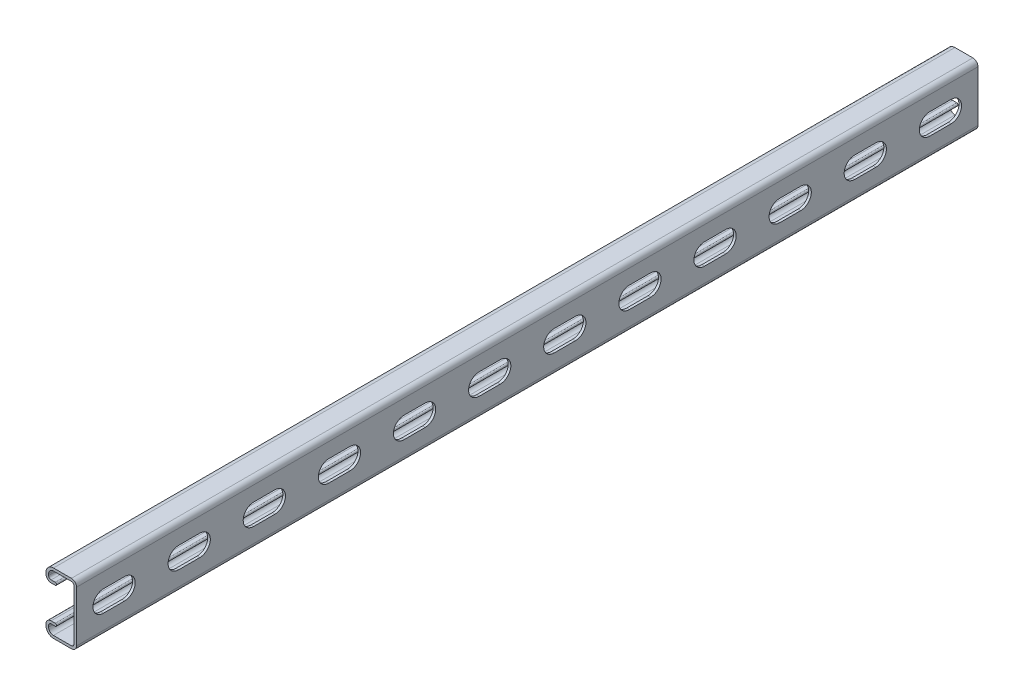
from build123d import *

# Parameters (mm, degrees)
BOSS_EXTRUDE1_DEPTH = 609.6
CUT_EXTRUDE1_DEPTH  = 1.778
LPATTERN1_COUNT     = 12
LPATTERN1_PITCH     = 50.8


with BuildPart() as part:
    # Sketch1 → Boss-Extrude1 (new body)
    with BuildSketch(Plane.XY):
        with BuildLine():
            Line((-15.58925, 20.6375), (-3.46075, 20.6375))
            ThreePointArc((-3.46075, 20.6375), (-1.013630207, 19.623869793), (0, 17.17675))
            Line((0, 17.17675), (0, -17.17675))
            ThreePointArc((0, -17.17675), (-1.013630207, -19.623869793), (-3.46075, -20.6375))
            Line((-3.46075, -20.6375), (-15.58925, -20.6375))
            ThreePointArc((-15.58925, -20.6375), (-19.158901808, -19.158901808), (-20.6375, -15.58925))
            Line((-20.6375, -15.58925), (-20.6375, -14.57325))
            ThreePointArc((-20.6375, -14.57325), (-19.623869793, -12.126130207), (-17.17675, -11.1125))
            Line((-17.17675, -11.1125), (-14.3891, -11.1125))
            ThreePointArc((-14.3891, -11.1125), (-13.5001, -12.0015), (-14.3891, -12.8905))
            Line((-14.3891, -12.8905), (-17.17675, -12.8905))
            ThreePointArc((-17.17675, -12.8905), (-18.366633936, -13.383366064), (-18.8595, -14.57325))
            Line((-18.8595, -14.57325), (-18.8595, -15.58925))
            ThreePointArc((-18.8595, -15.58925), (-17.901665951, -17.901665951), (-15.58925, -18.8595))
            Line((-15.58925, -18.8595), (-3.46075, -18.8595))
            ThreePointArc((-3.46075, -18.8595), (-2.270866064, -18.366633936), (-1.778, -17.17675))
            Line((-1.778, -17.17675), (-1.778, 17.17675))
            ThreePointArc((-1.778, 17.17675), (-2.270866064, 18.366633936), (-3.46075, 18.8595))
            Line((-3.46075, 18.8595), (-15.58925, 18.8595))
            ThreePointArc((-15.58925, 18.8595), (-17.901665951, 17.901665951), (-18.8595, 15.58925))
            Line((-18.8595, 15.58925), (-18.8595, 14.57325))
            ThreePointArc((-18.8595, 14.57325), (-18.366633936, 13.383366064), (-17.17675, 12.8905))
            Line((-17.17675, 12.8905), (-14.3891, 12.8905))
            ThreePointArc((-14.3891, 12.8905), (-13.5001, 12.0015), (-14.3891, 11.1125))
            Line((-14.3891, 11.1125), (-17.17675, 11.1125))
            ThreePointArc((-17.17675, 11.1125), (-19.623869793, 12.126130207), (-20.6375, 14.57325))
            Line((-20.6375, 14.57325), (-20.6375, 15.58925))
            ThreePointArc((-20.6375, 15.58925), (-19.158901808, 19.158901808), (-15.58925, 20.6375))
        make_face()
    extrude(amount=-BOSS_EXTRUDE1_DEPTH)

    # Sketch2 → Cut-Extrude1 (cut)
    with BuildSketch(Plane(origin=(0, 0, 0), x_dir=(0, 0, -1), z_dir=(1, 0, 0))):
        with BuildLine():
            Line((18.25625, 7.14375), (32.54375, 7.14375))
            ThreePointArc((32.54375, 7.14375), (39.6875, 0), (32.54375, -7.14375))
            Line((32.54375, -7.14375), (18.25625, -7.14375))
            ThreePointArc((18.25625, -7.14375), (11.1125, 0), (18.25625, 7.14375))
        make_face()
    cut_extrude1 = extrude(amount=-CUT_EXTRUDE1_DEPTH, mode=Mode.SUBTRACT)

    # LPattern1: Cut-Extrude1 ×12
    with Locations(*[(0, 0, -i * LPATTERN1_PITCH) for i in range(1, LPATTERN1_COUNT)]):
        add(cut_extrude1, mode=Mode.SUBTRACT)


solid = part.part
